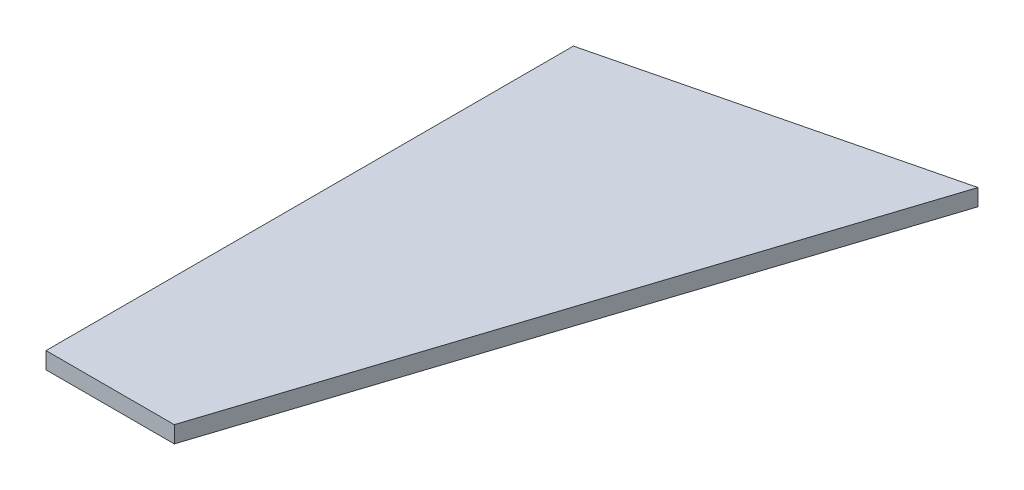
from build123d import *

# Parameters (mm, degrees)
BOSS_EXTRU_1_DEPTH = 2


with BuildPart() as part:
    # Esquisse1 → Boss.-Extru.1 (new body)
    with BuildSketch(Plane(origin=(0, 0, 0), x_dir=(1, 0, 0), z_dir=(0, 1, 0))):
        Polygon((38.904044699, 72.735324071), (0, 63.176869577), (0, 0), (15.369709253, 0), align=None)
    extrude(amount=BOSS_EXTRU_1_DEPTH)


solid = part.part
